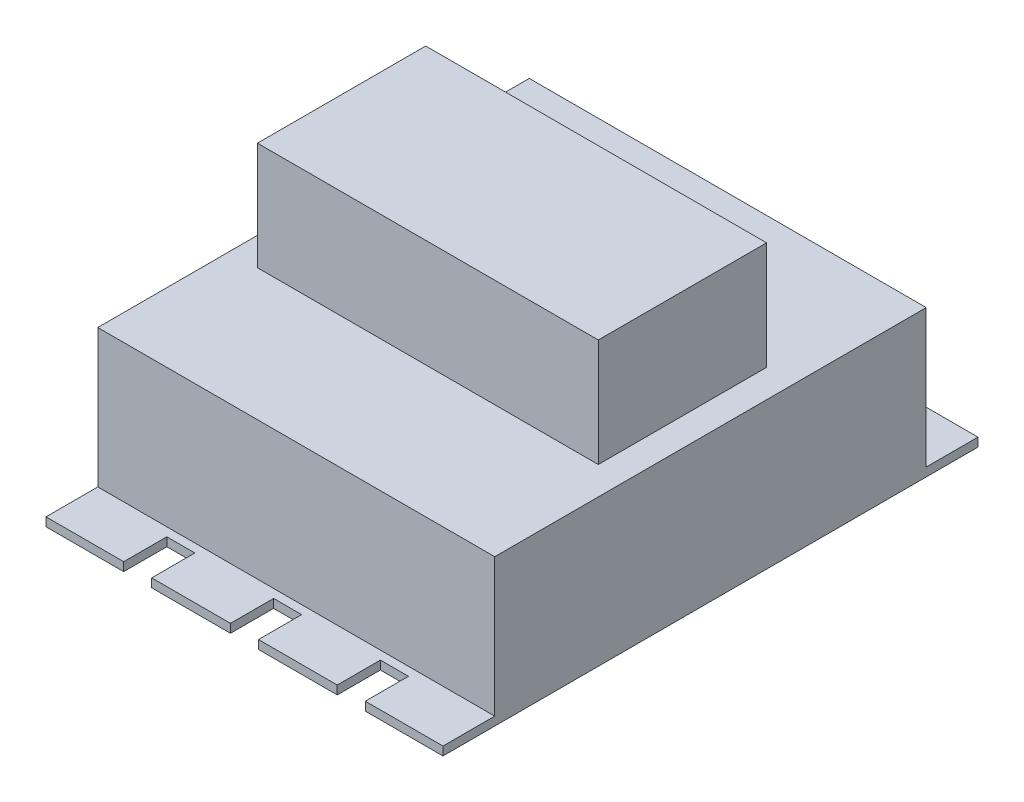
from build123d import *

# Parameters (mm, degrees)
SKETCH_1_W      = 92
SKETCH_1_H      = 100
EXTRUDE_1_DEPTH = 34
SKETCH_2_W      = 79
SKETCH_2_H      = 39
EXTRUDE_2_DEPTH = 25
EXTRUDE_3_DEPTH = 2


with BuildPart() as part:
    # Эскиз1 → Бобышка-Вытянуть1 (new body)
    with BuildSketch(Plane(origin=(0, 0, 0), x_dir=(1, 0, 0), z_dir=(0, 1, 0))):
        with Locations((46, 50)):
            Rectangle(SKETCH_1_W, SKETCH_1_H)
    extrude(amount=EXTRUDE_1_DEPTH)

    # Эскиз2 → Бобышка-Вытянуть2 (add)
    with BuildSketch(Plane(origin=(0, 34, 0), x_dir=(1, 0, 0), z_dir=(0, 1, 0))):
        with Locations((46, 50)):
            Rectangle(SKETCH_2_W, SKETCH_2_H)
    extrude(amount=EXTRUDE_2_DEPTH)

    # Эскиз3 → Бобышка-Вытянуть3 (add)
    with BuildSketch(Plane.XZ):
        Polygon((0, 12), (18, 12), (18, 2), (24.5, 2), (24.5, 12), (42.75, 12), (42.75, 2), (49.25, 2), (49.25, 12), (67.5, 12), (67.5, 2), (74, 2), (74, 12), (92, 12), (92, -112), (74, -112), (74, -102), (67.5, -102), (67.5, -112), (49.25, -112), (49.25, -102), (42.75, -102), (42.75, -112), (24.5, -112), (24.5, -102), (18, -102), (18, -112), (0, -112), align=None)
    extrude(amount=-EXTRUDE_3_DEPTH)


solid = part.part
